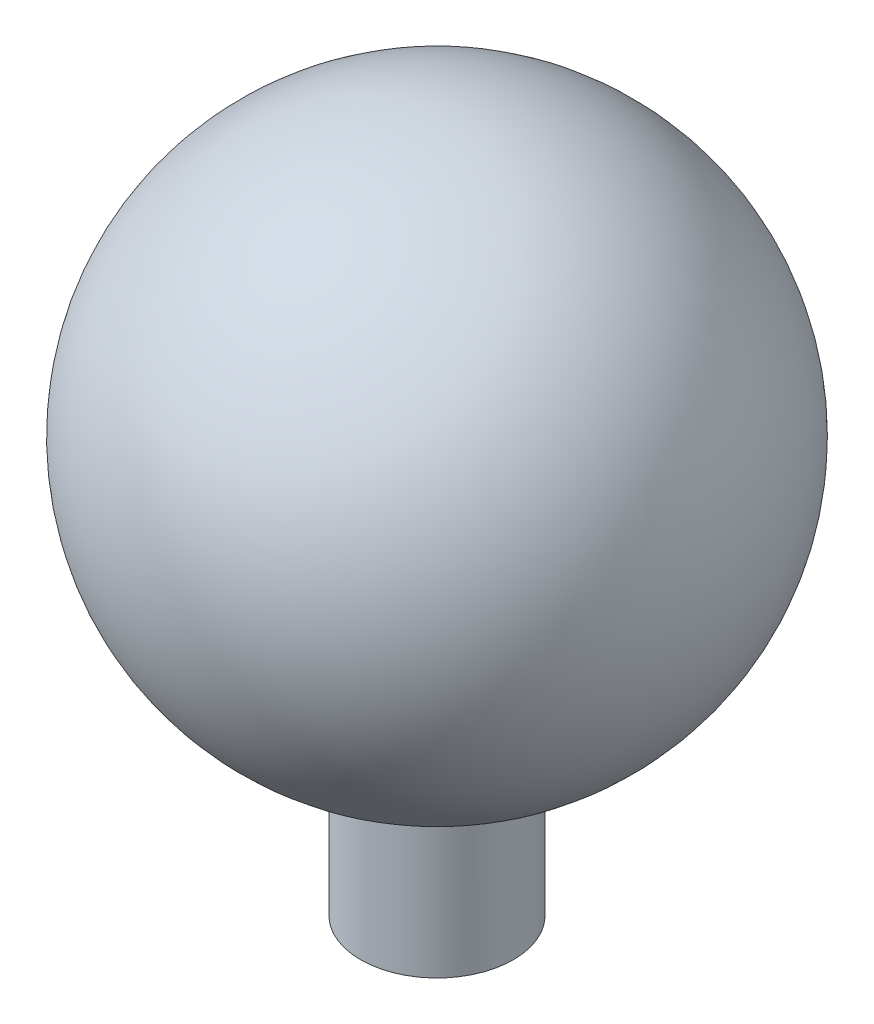
from build123d import *


with BuildPart() as part:
    # Sketch1 → Revolve1 (revolve)
    with BuildSketch(Plane.XY):
        with BuildLine():
            Line((0, 79.5), (0, -79.5))
            Line((0, -79.5), (0, -119.5))
            Line((0, -119.5), (22, -119.5))
            Line((22, -119.5), (22, -76.395353262))
            ThreePointArc((22, -76.395353262), (78.720012018, 11.108992206), (0, 79.5))
        make_face()
    revolve(axis=Axis((0, 79.5, 0), (0, -1, 0)))


solid = part.part
